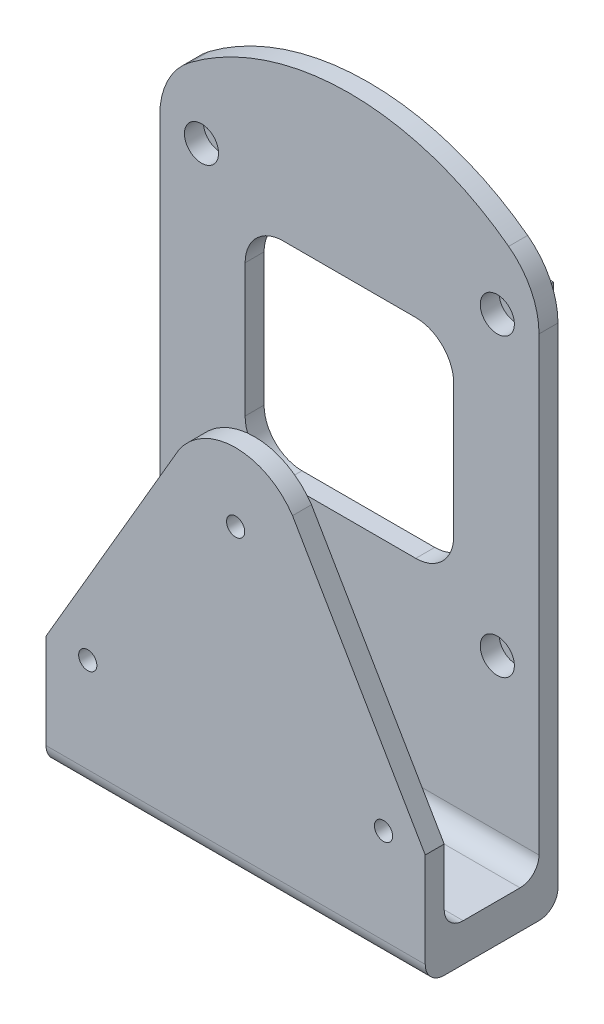
from build123d import *

# Parameters (mm, degrees)
SKETCH_1_R          = 4.5
EXTRUDE_2_DEPTH     = 5
FILLET1_R           = 20
SKETCH_1_5_W        = 12
SKETCH_1_5_H        = 11.85
SKETCH_1_5_R        = 2.5
BOSS_EXTRUDE1_DEPTH = 3.85
BOSS_EXTRUDE3_DEPTH = 5
SKETCH1_3_W         = 100
SKETCH1_3_H         = 10
BOSS_EXTRUDE4_DEPTH = 30
SKETCH2_R           = 2.4
BOSS_EXTRUDE5_DEPTH = 5
FILLET2_R           = 5


with BuildPart() as part:
    # Эскиз1 → Extrude 2 (new body)
    with BuildSketch(Plane.XY):
        with BuildLine():
            ThreePointArc((-50, -48.989794856), (0, -70), (50, -48.989794856))
            Line((50, -48.989794856), (50, 48.989794856))
            ThreePointArc((50, 48.989794856), (0, 70), (-50, 48.989794856))
            Line((-50, 48.989794856), (-50, -48.989794856))
        make_face()
        with BuildLine():
            ThreePointArc((27.5, -17.5), (24.571067812, -24.571067812), (17.5, -27.5))
            Line((17.5, -27.5), (-17.5, -27.5))
            ThreePointArc((-17.5, -27.5), (-24.571067812, -24.571067812), (-27.5, -17.5))
            Line((-27.5, -17.5), (-27.5, 17.5))
            ThreePointArc((-27.5, 17.5), (-24.571067812, 24.571067812), (-17.5, 27.5))
            Line((-17.5, 27.5), (17.5, 27.5))
            ThreePointArc((17.5, 27.5), (24.571067812, 24.571067812), (27.5, 17.5))
            Line((27.5, 17.5), (27.5, -17.5))
        make_face(mode=Mode.SUBTRACT)
        with Locations((-39, -39)):
            Circle(SKETCH_1_R, mode=Mode.SUBTRACT)
        with Locations((-39, 39)):
            Circle(SKETCH_1_R, mode=Mode.SUBTRACT)
        with Locations((39, 39)):
            Circle(SKETCH_1_R, mode=Mode.SUBTRACT)
        with Locations((39, -39)):
            Circle(SKETCH_1_R, mode=Mode.SUBTRACT)
    extrude(amount=EXTRUDE_2_DEPTH)

    # Fillet1
    fillet1_edges = [part.edges().sort_by_distance(p)[0] for p in [
        (50, -48.989794856, 2.5),
        (-50, -48.989794856, 2.5),
        (-50, 48.989794856, 2.5),
        (50, 48.989794856, 2.5),
    ]]
    fillet(fillet1_edges, radius=FILLET1_R)

    # Эскиз1<5> → Boss-Extrude1 (add)
    # profile 1 of 4: a face of its own
    with BuildSketch(Plane.XY):
        with Locations((39, -39)):
            Rectangle(SKETCH_1_5_W, SKETCH_1_5_H)
        with Locations((39, -39)):
            Circle(SKETCH_1_5_R, mode=Mode.SUBTRACT)
    # profile 2 of 4: a face of its own
    with BuildSketch(Plane.XY):
        with Locations((-39, -39)):
            Rectangle(SKETCH_1_5_W, SKETCH_1_5_H)
        with Locations((-39, -39)):
            Circle(SKETCH_1_5_R, mode=Mode.SUBTRACT)
    # profile 3 of 4: a face of its own
    with BuildSketch(Plane.XY):
        with Locations((39, 39)):
            Rectangle(SKETCH_1_5_W, SKETCH_1_5_H)
        with Locations((39, 39)):
            Circle(SKETCH_1_5_R, mode=Mode.SUBTRACT)
    # profile 4 of 4: a face of its own
    with BuildSketch(Plane.XY):
        with Locations((-39, 39)):
            Rectangle(SKETCH_1_5_W, SKETCH_1_5_H)
        with Locations((-39, 39)):
            Circle(SKETCH_1_5_R, mode=Mode.SUBTRACT)
    extrude(amount=-BOSS_EXTRUDE1_DEPTH)

    # Sketch1 → Boss-Extrude3 (add)
    with BuildSketch(Plane.XY):
        with BuildLine():
            ThreePointArc((50, -40), (0, -60.710678119), (-50, -40))
            Line((-50, -40), (-50, -84))
            Line((-50, -84), (50, -84))
            Line((50, -84), (50, -40))
        make_face()
    extrude(amount=BOSS_EXTRUDE3_DEPTH)

    # Sketch1_3 → Boss-Extrude4 (add)
    with BuildSketch(Plane.XY):
        with Locations((0, -89)):
            Rectangle(SKETCH1_3_W, SKETCH1_3_H)
    extrude(amount=BOSS_EXTRUDE4_DEPTH)

    # Sketch2 → Boss-Extrude5 (add)
    with BuildSketch(Plane.XY.offset(30)):
        with BuildLine():
            Line((-50, -64), (-50, -94))
            Line((-50, -94), (50, -94))
            Line((50, -94), (50, -64))
            Line((50, -64), (15, -4))
            ThreePointArc((15, -4), (0, 4.027756377), (-15, -4))
            Line((-15, -4), (-50, -64))
        make_face()
        with Locations((-39, -64)):
            Circle(SKETCH2_R, mode=Mode.SUBTRACT)
        with Locations((39, -64)):
            Circle(SKETCH2_R, mode=Mode.SUBTRACT)
        with Locations((0, -14)):
            Circle(SKETCH2_R, mode=Mode.SUBTRACT)
    extrude(amount=BOSS_EXTRUDE5_DEPTH)

    # Fillet2
    fillet2_edges = [part.edges().sort_by_distance(p)[0] for p in [
        (0, -94, 0),
        (0, -94, 35),
        (0, -84, 30),
        (0, -84, 5),
    ]]
    fillet(fillet2_edges, radius=FILLET2_R)


solid = part.part
